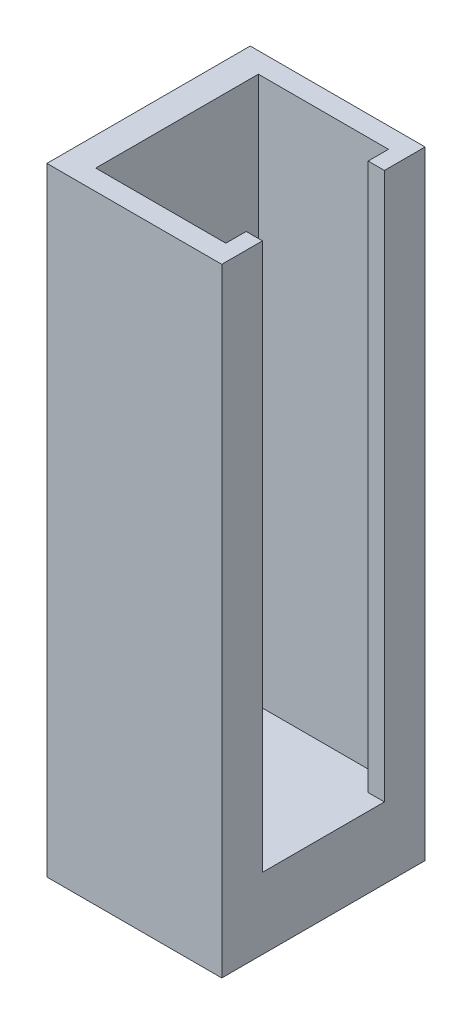
from build123d import *

# Parameters (mm, degrees)
SKETCH1_W           = 4.3
SKETCH1_H           = 15.2
BOSS_EXTRUDE1_DEPTH = 2.5
CUT_EXTRUDE1_START  = -1.75
CUT_EXTRUDE1_DEPTH  = 14.45


with BuildPart() as part:
    # Sketch1 → Boss-Extrude1 (new body, symmetric)
    with BuildSketch(Plane.XY):
        with Locations((0, 7.6)):
            Rectangle(SKETCH1_W, SKETCH1_H)
    extrude(amount=BOSS_EXTRUDE1_DEPTH, both=True)

    # Sketch3 → Cut-Extrude1 (cut, through all)
    with BuildSketch(Plane(origin=(0, 0, 0), x_dir=(-1, 0, 0), z_dir=(0, -1, 0)).offset(CUT_EXTRUDE1_START)):
        Polygon((-2.15, -1.5), (-1.75, -1.5), (-1.75, -2), (1.45, -2), (1.45, 2), (-1.75, 2), (-1.75, 1.5), (-2.15, 1.5), align=None)
    extrude(amount=-CUT_EXTRUDE1_DEPTH, mode=Mode.SUBTRACT)


solid = part.part
